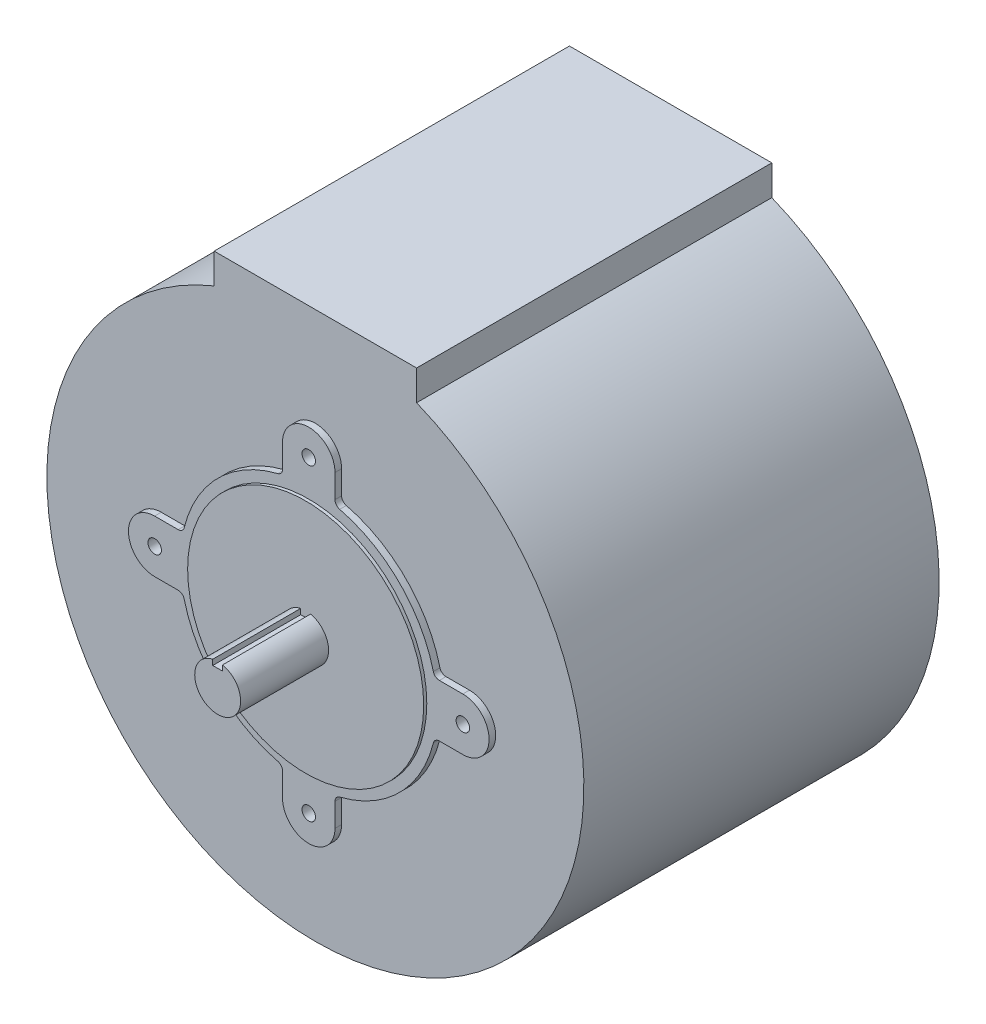
from build123d import *

# Parameters (mm, degrees)
SKETCH1_R                    = 130
BOSS_EXTRUDE1_DEPTH          = 172
BOSS_EXTRUDE2_DEPTH          = 3.2
SKETCH3_R                    = 57.15
BOSS_EXTRUDE3_DEPTH          = 1.5
F_5_16_18_TAPPED_HOLE1_D     = 6.5278
F_5_16_18_TAPPED_HOLE1_DEPTH = 20.1091
F_5_16_18_TAPPED_HOLE1_TIP   = 1.961148974
SKETCH6_W                    = 98
SKETCH6_H                    = 47.7
BOSS_EXTRUDE4_DEPTH          = 172
BOSS_EXTRUDE5_DEPTH          = 42.6


with BuildPart() as part:
    # Sketch1 → Boss-Extrude1 (new body)
    with BuildSketch(Plane.XY):
        Circle(SKETCH1_R)
    extrude(amount=-BOSS_EXTRUDE1_DEPTH)

    # Sketch2 → Boss-Extrude2 (add)
    with BuildSketch(Plane.XY):
        with BuildLine():
            Line((-63.229996837, 12.7), (-74.6, 12.7))
            ThreePointArc((-74.6, 12.7), (-87.3, 0), (-74.6, -12.7))
            Line((-74.6, -12.7), (-63.229996837, -12.7))
            ThreePointArc((-63.229996837, -12.7), (-61.381868207, -13.336862135), (-60.318408341, -14.977052955))
            ThreePointArc((-60.318408341, -14.977052955), (-43.946686451, -43.946686451), (-14.977052955, -60.318408341))
            ThreePointArc((-14.977052955, -60.318408341), (-13.336862135, -61.381868207), (-12.7, -63.229996837))
            Line((-12.7, -63.229996837), (-12.7, -74.6))
            ThreePointArc((-12.7, -74.6), (0, -87.3), (12.7, -74.6))
            Line((12.7, -74.6), (12.7, -63.229996837))
            ThreePointArc((12.7, -63.229996837), (13.336862135, -61.381868207), (14.977052955, -60.318408341))
            ThreePointArc((14.977052955, -60.318408341), (43.946686451, -43.946686451), (60.318408341, -14.977052955))
            ThreePointArc((60.318408341, -14.977052955), (61.381868207, -13.336862135), (63.229996837, -12.7))
            Line((63.229996837, -12.7), (74.6, -12.7))
            ThreePointArc((74.6, -12.7), (87.3, 0), (74.6, 12.7))
            Line((74.6, 12.7), (63.229996837, 12.7))
            ThreePointArc((63.229996837, 12.7), (61.381868207, 13.336862135), (60.318408341, 14.977052955))
            ThreePointArc((60.318408341, 14.977052955), (43.946686451, 43.946686451), (14.977052955, 60.318408341))
            ThreePointArc((14.977052955, 60.318408341), (13.336862135, 61.381868207), (12.7, 63.229996837))
            Line((12.7, 63.229996837), (12.7, 74.6))
            ThreePointArc((12.7, 74.6), (0, 87.3), (-12.7, 74.6))
            Line((-12.7, 74.6), (-12.7, 63.229996837))
            ThreePointArc((-12.7, 63.229996837), (-13.336862135, 61.381868207), (-14.977052955, 60.318408341))
            ThreePointArc((-14.977052955, 60.318408341), (-43.946686451, 43.946686451), (-60.318408341, 14.977052955))
            ThreePointArc((-60.318408341, 14.977052955), (-61.381868207, 13.336862135), (-63.229996837, 12.7))
        make_face()
    extrude(amount=BOSS_EXTRUDE2_DEPTH)

    # Sketch3 → Boss-Extrude3 (add)
    with BuildSketch(Plane.XY.offset(3.2)):
        Circle(SKETCH3_R)
    extrude(amount=BOSS_EXTRUDE3_DEPTH)

    # 5/16-18 Tapped Hole1
    with Locations(Plane.XY.offset(3.2)):
        with Locations((-74.6, 0), (0, 74.6), (74.6, 0), (0, -74.6)):
            Hole(F_5_16_18_TAPPED_HOLE1_D / 2, depth=F_5_16_18_TAPPED_HOLE1_DEPTH)
            with Locations((0, 0, -(F_5_16_18_TAPPED_HOLE1_DEPTH + F_5_16_18_TAPPED_HOLE1_TIP / 2))):  # 118° drill point
                Cone(0, F_5_16_18_TAPPED_HOLE1_D / 2, F_5_16_18_TAPPED_HOLE1_TIP, mode=Mode.SUBTRACT)

    # Sketch6 → Boss-Extrude4 (add)
    with BuildSketch(Plane.XY):
        with Locations((0, 111.15)):
            Rectangle(SKETCH6_W, SKETCH6_H)
    extrude(amount=-BOSS_EXTRUDE4_DEPTH)

    # Sketch7 → Boss-Extrude5 (add)
    with BuildSketch(Plane.XY.offset(4.7)):
        with BuildLine():
            Line((-2.39, 10.855004606), (-2.39, 8.205004606))
            Line((-2.39, 8.205004606), (2.39, 8.205004606))
            Line((2.39, 8.205004606), (2.39, 10.855004606))
            ThreePointArc((2.39, 10.855004606), (0, -11.115), (-2.39, 10.855004606))
        make_face()
    extrude(amount=BOSS_EXTRUDE5_DEPTH)


solid = part.part
